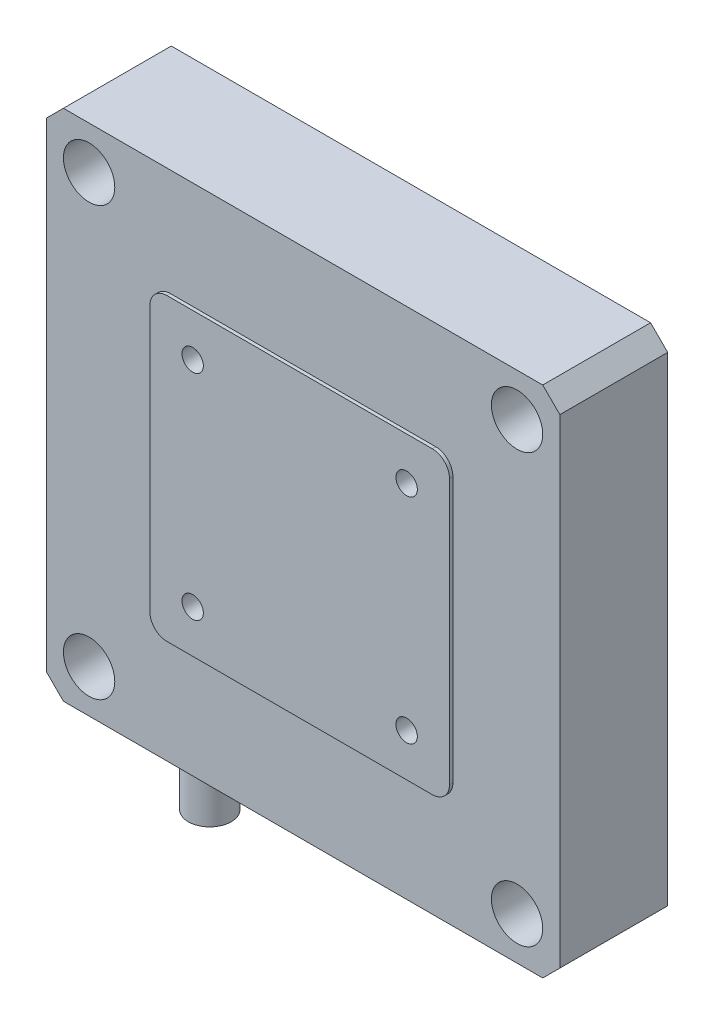
from build123d import *

# Parameters (mm, degrees)
SKETCH_1_W                = 60
SKETCH_1_H                = 60
EXTRUDE_1_DEPTH           = 12.6
CHAMFER_1_SIZE            = 2
SKETCH_2_W                = 35
SKETCH_2_H                = 35
EXTRUDE_2_DEPTH           = 0.4
FILLET_1_R                = 2
HOLE_WIZARD_1_D           = 3.4
HOLE_WIZARD_1_CBORE_D     = 6
HOLE_WIZARD_1_CBORE_DEPTH = 5
HOLE_WIZARD_M3_1_D        = 2.5
HOLE_WIZARD_M3_1_DEPTH    = 3.5
HOLE_WIZARD_M3_1_TIP      = 0.751075774
SKETCH_7_R                = 2.5
EXTRUDE_3_DEPTH           = 10


with BuildPart() as part:
    # 草图1 → 凸台-拉伸1 (new body)
    with BuildSketch(Plane.XY):
        Rectangle(SKETCH_1_W, SKETCH_1_H)
    extrude(amount=EXTRUDE_1_DEPTH)

    # 倒角1
    chamfer_1_edges = [part.edges().sort_by_distance(p)[0] for p in [
        (30, -30, 6.3),
        (-30, -30, 6.3),
        (-30, 30, 6.3),
        (30, 30, 6.3),
    ]]
    chamfer(chamfer_1_edges, length=CHAMFER_1_SIZE)

    # 草图2 → 凸台-拉伸2 (add)
    with BuildSketch(Plane.XY.offset(12.6)):
        Rectangle(SKETCH_2_W, SKETCH_2_H)
    extrude(amount=EXTRUDE_2_DEPTH)

    # 圆角1
    fillet_1_edges = [part.edges().sort_by_distance(p)[0] for p in [
        (17.5, -17.5, 12.8),
        (17.5, 17.5, 12.8),
        (-17.5, 17.5, 12.8),
        (-17.5, -17.5, 12.8),
    ]]
    fillet(fillet_1_edges, radius=FILLET_1_R)

    # 孔1 (through all)
    with Locations(Plane(origin=(-25, 25, 12.6), x_dir=(1, 0, 0), z_dir=(0, 0, 1))):
        with Locations((0, 0), (50, 0), (0, -50), (50, -50)):
            CounterBoreHole(HOLE_WIZARD_1_D / 2, HOLE_WIZARD_1_CBORE_D / 2, HOLE_WIZARD_1_CBORE_DEPTH)

    # M3 螺纹孔1
    with Locations(Plane(origin=(-12.5, 12.5, 13), x_dir=(1, 0, 0), z_dir=(0, 0, 1))):
        with Locations((0, 0), (25, 0), (25, -25), (0, -25)):
            Hole(HOLE_WIZARD_M3_1_D / 2, depth=HOLE_WIZARD_M3_1_DEPTH)
            with Locations((0, 0, -(HOLE_WIZARD_M3_1_DEPTH + HOLE_WIZARD_M3_1_TIP / 2))):  # 118° drill point
                Cone(0, HOLE_WIZARD_M3_1_D / 2, HOLE_WIZARD_M3_1_TIP, mode=Mode.SUBTRACT)

    # 草图7 → 凸台-拉伸3 (add)
    with BuildSketch(Plane.XZ.offset(30)):
        with Locations((-18.5, 5)):
            Circle(SKETCH_7_R)
    extrude(amount=EXTRUDE_3_DEPTH)


solid = part.part
